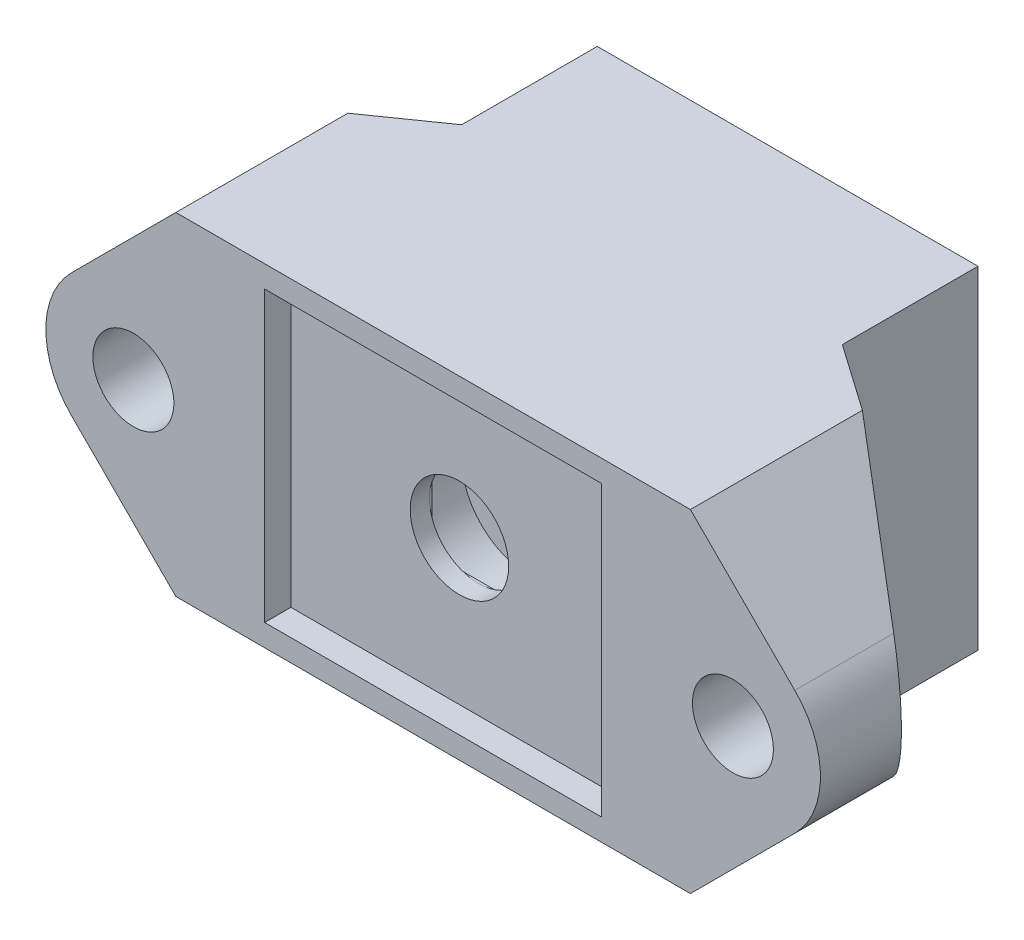
from build123d import *

# Parameters (mm, degrees)
SKETCH1_W           = 17.4
SKETCH1_H           = 15.2
SKETCH1_R           = 1.65
BOSS_EXTRUDE1_DEPTH = 5
SKETCH2_W           = 17.4
SKETCH2_H           = 15.2
SKETCH2_W_2         = 15.4
SKETCH2_H_2         = 13.2
BOSS_EXTRUDE2_DEPTH = 1.2
CUT_EXTRUDE1_START  = -1
SKETCH3_R           = 3.1
CUT_EXTRUDE1_DEPTH  = 2.2
SKETCH4_R           = 2.25
CUT_EXTRUDE2_DEPTH  = 1
SKETCH6_W           = 4.5
SKETCH6_H           = 4.5
CUT_EXTRUDE4_DEPTH  = 0.12
SKETCH7_W           = 17.4
SKETCH7_H           = 15.2
SKETCH7_R           = 4.23
BOSS_EXTRUDE3_DEPTH = 10
CHAMFER1_SIZE       = 3
CHAMFER1_SIZE2      = 0.528980942
SKETCH9_R           = 1.85
BOSS_EXTRUDE5_DEPTH = 10
CUT_EXTRUDE5_DEPTH  = 16.2
CHAMFER3_SIZE       = 1.4
CHAMFER3_SIZE2      = 2.424871131


with BuildPart() as part:
    # Sketch1 → Boss-Extrude1 (new body)
    with BuildSketch(Plane.XY):
        Rectangle(SKETCH1_W, SKETCH1_H)
        Circle(SKETCH1_R, mode=Mode.SUBTRACT)
    extrude(amount=BOSS_EXTRUDE1_DEPTH)

    # Sketch2 → Boss-Extrude2 (add)
    with BuildSketch(Plane.XY.offset(5)):
        Rectangle(SKETCH2_W, SKETCH2_H)
        Rectangle(SKETCH2_W_2, SKETCH2_H_2, mode=Mode.SUBTRACT)
    extrude(amount=BOSS_EXTRUDE2_DEPTH)

    # Sketch3 → Cut-Extrude1 (cut)
    with BuildSketch(Plane.XY.offset(5).offset(CUT_EXTRUDE1_START)):
        Circle(SKETCH3_R)
    extrude(amount=-CUT_EXTRUDE1_DEPTH, mode=Mode.SUBTRACT)

    # Sketch4 → Cut-Extrude2 (cut)
    with BuildSketch(Plane.XY.offset(5)):
        Circle(SKETCH4_R)
    extrude(amount=-CUT_EXTRUDE2_DEPTH, mode=Mode.SUBTRACT)

    # Sketch6 → Cut-Extrude4 (cut)
    with BuildSketch(Plane(origin=(0, 0, 4), x_dir=(-1, 0, 0), z_dir=(0, 0, -1))):
        Rectangle(SKETCH6_W, SKETCH6_H)
    extrude(amount=-CUT_EXTRUDE4_DEPTH, mode=Mode.SUBTRACT)

    # Sketch7 → Boss-Extrude3 (add)
    with BuildSketch(Plane(origin=(0, 0, 0), x_dir=(-1, 0, 0), z_dir=(0, 0, -1))):
        Rectangle(SKETCH7_W, SKETCH7_H)
        Circle(SKETCH7_R, mode=Mode.SUBTRACT)
    extrude(amount=BOSS_EXTRUDE3_DEPTH)

    # Chamfer1
    chamfer1_edges = [part.edges().sort_by_distance(p)[0] for p in [
        (4.23, 0, -10),
    ]]
    chamfer1_side = [part.faces().sort_by_distance(p)[0] for p in [
        (4.23, 0, -5),
    ]]
    chamfer(chamfer1_edges, length=CHAMFER1_SIZE, length2=CHAMFER1_SIZE2, reference=chamfer1_side[0])

    # Sketch9 → Boss-Extrude5 (add)
    with BuildSketch(Plane.XY.offset(6.2)):
        with BuildLine():
            Line((8.7, 7.6), (8.7, -7.6))
            Line((8.7, -7.6), (11.756854249, -7.6))
            Line((11.756854249, -7.6), (16.528427125, -2.828427125))
            ThreePointArc((16.528427125, -2.828427125), (17.7, 0), (16.528427125, 2.828427125))
            Line((16.528427125, 2.828427125), (11.756854249, 7.6))
            Line((11.756854249, 7.6), (8.7, 7.6))
        make_face()
        with Locations((13.7, 0)):
            Circle(SKETCH9_R, mode=Mode.SUBTRACT)
        with BuildLine():
            Line((-8.7, 7.6), (-8.7, -7.6))
            Line((-8.7, -7.6), (-11.756854249, -7.6))
            Line((-11.756854249, -7.6), (-16.528427125, -2.828427125))
            ThreePointArc((-16.528427125, -2.828427125), (-17.7, 0), (-16.528427125, 2.828427125))
            Line((-16.528427125, 2.828427125), (-11.756854249, 7.6))
            Line((-11.756854249, 7.6), (-8.7, 7.6))
        make_face()
        with Locations((-13.7, 0)):
            Circle(SKETCH9_R, mode=Mode.SUBTRACT)
    extrude(amount=-BOSS_EXTRUDE5_DEPTH)

    # Sketch10 → Cut-Extrude5 (cut, through all)
    with BuildSketch(Plane.XZ.offset(7.6)):
        Polygon((-8.7, -3.8), (-19.607158184, 3.837274381), (-19.607158184, -3.8), align=None)
        Polygon((19.607158184, -3.8), (8.7, -3.8), (19.607158184, 3.837274381), align=None)
    extrude(amount=-CUT_EXTRUDE5_DEPTH, mode=Mode.SUBTRACT)

    # Chamfer3
    chamfer3_edges = [part.edges().sort_by_distance(p)[0] for p in [
        (4.23, 0, 0),
    ]]
    chamfer3_side = [part.faces().sort_by_distance(p)[0] for p in [
        (4.23, 0, -3.5),
    ]]
    chamfer(chamfer3_edges, length=CHAMFER3_SIZE, length2=CHAMFER3_SIZE2, reference=chamfer3_side[0])


solid = part.part
